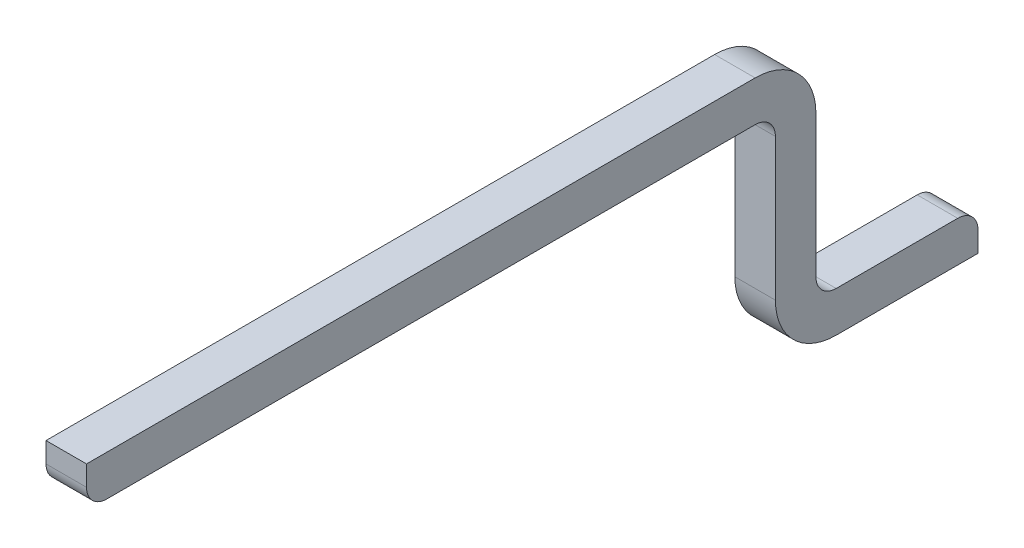
from build123d import *

# Parameters (mm, degrees)
EXTRUDE_THIN1_DEPTH = 0.1
FILLET1_R           = 0.1


with BuildPart() as part:
    # Sketch1 → Extrude-Thin1 (new body, symmetric)
    with BuildSketch(Plane(origin=(0, 0, 0), x_dir=(0, 0, -1), z_dir=(1, 0, 0))):
        with BuildLine():
            Line((0.8, 1.1), (4.1, 1.1))
            ThreePointArc((4.1, 1.1), (4.170710678, 1.070710678), (4.2, 1))
            Line((4.2, 1), (4.2, 0.3))
            ThreePointArc((4.2, 0.3), (4.287867966, 0.087867966), (4.5, 0))
            Line((4.5, 0), (5.2, 0))
            Line((5.2, 0), (5.2, 0.2))
            Line((5.2, 0.2), (4.5, 0.2))
            ThreePointArc((4.5, 0.2), (4.429289322, 0.229289322), (4.4, 0.3))
            Line((4.4, 0.3), (4.4, 1))
            ThreePointArc((4.4, 1), (4.312132034, 1.212132034), (4.1, 1.3))
            Line((4.1, 1.3), (0.8, 1.3))
            Line((0.8, 1.3), (0.8, 1.1))
        make_face()
    extrude(amount=EXTRUDE_THIN1_DEPTH, both=True)

    # Fillet1
    fillet1_edges = [part.edges().sort_by_distance(p)[0] for p in [
        (0, 1.1, -0.8),
        (0, 0.2, -5.2),
    ]]
    fillet(fillet1_edges, radius=FILLET1_R)


solid = part.part
